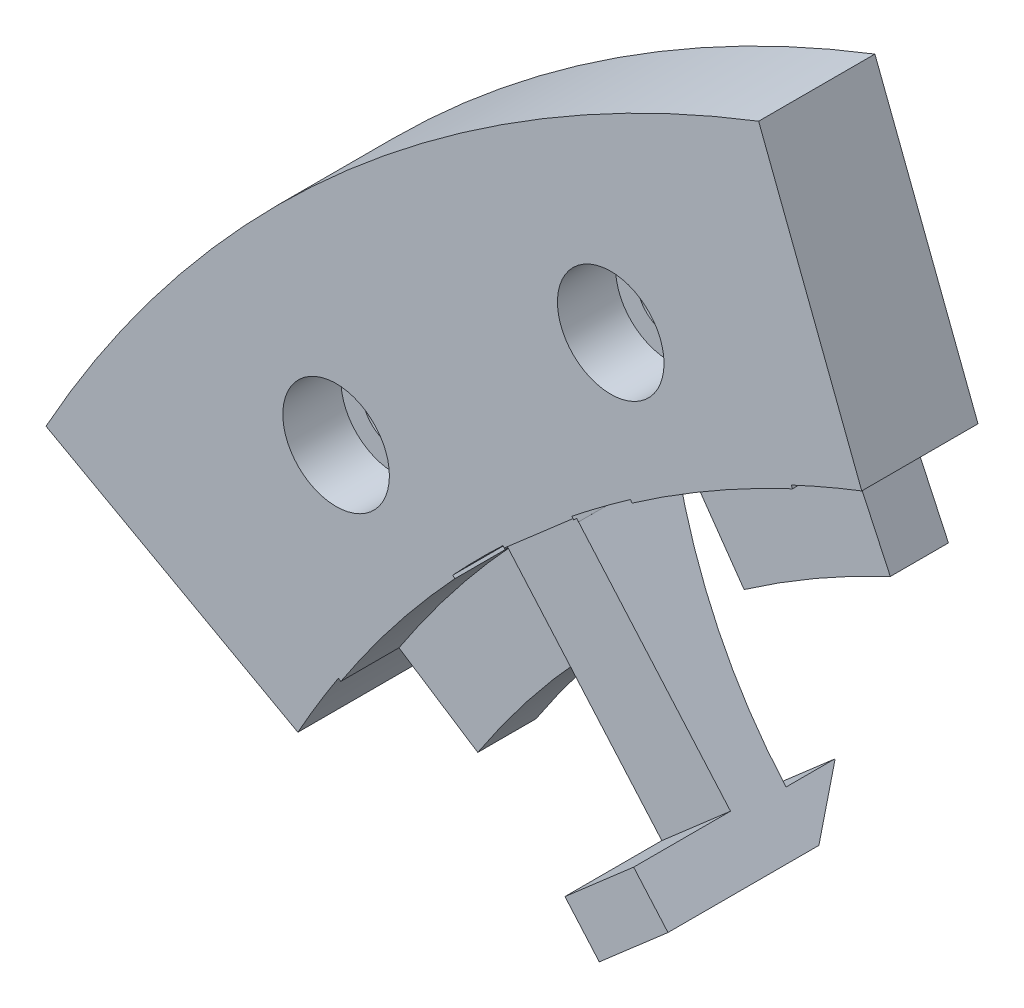
from build123d import *

# Parameters (mm, degrees)
BOSS_EXTRUDE1_DEPTH      = 6
SKETCH4_R                = 1.65
CUT_EXTRUDE1_DEPTH       = 92.758963041
BOSS_EXTRUDE2_DEPTH      = 2.5
BOSS_EXTRUDE2_DEPTH_BACK = 2.5
FILLET1_R                = 0.1
BOSS_EXTRUDE3_DEPTH      = 3
SKETCH9_R                = 2.75
CUT_EXTRUDE2_DEPTH       = 3
TOLERANCECUT_DEPTH       = 93.220969961
TOLERANCECUT2_DEPTH      = 2.35
TOLERANCECUT2_DEPTH_BACK = 2.35
CUT_EXTRUDE_THIN1_DEPTH  = 10


with BuildPart() as part:
    # Sketch1 → Boss-Extrude1 (new body)
    with BuildSketch(Plane(origin=(0, 0, 0), x_dir=(0, 1, 0), z_dir=(0, 0, 1))):
        with BuildLine():
            Line((66.793011614, 25.63943495), (52.789305216, 20.263915707))
            ThreePointArc((52.789305216, 20.263915707), (42.645904251, 37.130363258), (27.335841873, 49.498371429))
            Line((27.335841873, 49.498371429), (34.587369472, 62.629073903))
            ThreePointArc((34.587369472, 62.629073903), (53.95881545, 46.980136869), (66.793011614, 25.63943495))
        make_face()
    extrude(amount=BOSS_EXTRUDE1_DEPTH)

    # Sketch4 → Cut-Extrude1 (cut, through all)
    with BuildSketch(Plane(origin=(0, 0, 0), x_dir=(0, 1, 0), z_dir=(0, 0, 1))):
        with Locations((41.364521778, 47.584439033)):
            Circle(SKETCH4_R)
        with Locations((53.469432463, 33.41140961)):
            Circle(SKETCH4_R)
    extrude(amount=CUT_EXTRUDE1_DEPTH, mode=Mode.SUBTRACT)

    # Sketch7 → Boss-Extrude2 (add, two sides: drawn at the far end of the back side and taken through both)
    with BuildSketch(Plane(origin=(0, 0, 0), x_dir=(0, 0, 1), z_dir=(-0.7541940799479068, -0.6566515741026824, 0)).offset(-BOSS_EXTRUDE2_DEPTH_BACK)):
        with BuildLine():
            Line((6, 41.545), (3, 41.545))
            Line((3, 41.545), (0.5, 44.045))
            Line((0.5, 44.045), (0.5, 44.295))
            Line((0.5, 44.295), (3, 44.295))
            ThreePointArc((3, 44.295), (2.368624388, 50.546249875), (0.5, 56.545))
            Line((0.5, 56.545), (6, 56.545))
            Line((6, 56.545), (6, 44.545))
            Line((6, 44.545), (11, 44.545))
            Line((11, 44.545), (11, 41.545))
            Line((11, 41.545), (6, 41.545))
        make_face()
    extrude(amount=BOSS_EXTRUDE2_DEPTH + BOSS_EXTRUDE2_DEPTH_BACK)

    # Fillet1
    fillet1_edges = [part.edges().sort_by_distance(p)[0] for p in [
        (-29.086381475, 33.407026771, 3),
        (-29.250544368, 33.595575291, 6),
        (-37.130363258, 42.645904251, 0.5),
    ]]
    fillet(fillet1_edges, radius=FILLET1_R)

    # Sketch8 → Boss-Extrude3 (add)
    with BuildSketch(Plane(origin=(0, 0, 0), x_dir=(0, 1, 0), z_dir=(0, 0, 1))):
        with BuildLine():
            ThreePointArc((38.56359727, 41.354395058), (34.812578122, 44.558068063), (30.796614235, 47.422627264))
            Line((30.796614235, 47.422627264), (28.07341906, 43.229274425))
            ThreePointArc((28.07341906, 43.229274425), (31.734270746, 40.618014295), (35.153605469, 37.69762655))
            Line((35.153605469, 37.69762655), (38.56359727, 41.354395058))
        make_face()
        with BuildLine():
            ThreePointArc((51.247173818, 23.89694961), (48.969406457, 28.2725), (46.318952344, 32.432879593))
            Line((46.318952344, 32.432879593), (42.223192123, 29.564997412))
            ThreePointArc((42.223192123, 29.564997412), (44.639279438, 25.7725), (46.715634883, 21.783858301))
            Line((46.715634883, 21.783858301), (51.247173818, 23.89694961))
        make_face()
    extrude(amount=BOSS_EXTRUDE3_DEPTH)

    # Sketch9 → Cut-Extrude2 (cut)
    with BuildSketch(Plane.XY.offset(6)):
        with Locations((-47.584439033, 41.364521778)):
            Circle(SKETCH9_R)
        with Locations((-33.41140961, 53.469432463)):
            Circle(SKETCH9_R)
    extrude(amount=-CUT_EXTRUDE2_DEPTH, mode=Mode.SUBTRACT)

    # Sketch10 → ToleranceCut (cut, through all)
    with BuildSketch(Plane(origin=(0, 0, 0), x_dir=(0, 1, 0), z_dir=(0, 0, 1))):
        with BuildLine():
            Line((38.453894214, 41.456694812), (35.14605375, 37.9094702))
            ThreePointArc((35.14605375, 37.9094702), (31.826619967, 40.736215908), (28.280796974, 43.273196641))
            Line((28.280796974, 43.273196641), (30.92241482, 47.340931409))
            Line((30.92241482, 47.340931409), (30.67081365, 47.50432312))
            Line((30.67081365, 47.50432312), (27.865803402, 43.184986115))
            ThreePointArc((27.865803402, 43.184986115), (31.641921524, 40.499812682), (35.160859486, 37.485463652))
            Line((35.160859486, 37.485463652), (38.673300325, 41.252095304))
            Line((38.673300325, 41.252095304), (38.453894214, 41.456694812))
        make_face()
        with BuildLine():
            Line((46.232915879, 32.5557524), (42.014103544, 29.601708201))
            ThreePointArc((42.014103544, 29.601708201), (44.509375628, 25.6975), (46.642883069, 21.584426886))
            Line((46.642883069, 21.584426886), (51.310566557, 23.761003442))
            Line((51.310566557, 23.761003442), (51.183781079, 24.032895778))
            Line((51.183781079, 24.032895778), (46.787991078, 21.983105237))
            ThreePointArc((46.787991078, 21.983105237), (44.769183249, 25.8475), (42.431923129, 29.528036247))
            Line((42.431923129, 29.528036247), (46.40498881, 32.310006787))
            Line((46.40498881, 32.310006787), (46.232915879, 32.5557524))
        make_face()
        Polygon((44.147333984, 35.321699097), (32.876124251, 25.508233558), (33.073119723, 25.281975334), (44.344329456, 35.095440873), align=None)
        Polygon((40.817854097, 39.052425533), (29.59286638, 29.279203958), (29.789861852, 29.052945734), (41.014849569, 38.826167309), align=None)
    extrude(amount=TOLERANCECUT_DEPTH, mode=Mode.SUBTRACT)

    # Sketch16 → ToleranceCut2 (cut, two sides: drawn at the far end of the back side and taken through both)
    with BuildSketch(Plane(origin=(0, 0, 0), x_dir=(0, 0, 1), z_dir=(-0.7541940799479068, -0.6566515741026824, 0)).offset(-TOLERANCECUT2_DEPTH_BACK)):
        with BuildLine():
            Line((5.85, 56.545), (5.85, 44.395))
            Line((5.85, 44.395), (10.85, 44.395))
            Line((10.85, 44.395), (10.85, 41.695))
            Line((10.85, 41.695), (6, 41.695))
            Line((6, 41.695), (3.062132034, 41.695))
            Line((3.062132034, 41.695), (0.65, 44.107132034))
            Line((0.65, 44.107132034), (0.65, 44.145))
            Line((0.65, 44.145), (3.14964186, 44.145))
            ThreePointArc((3.14964186, 44.145), (2.530504313, 50.50274046), (0.638004798, 56.603776489))
            Line((0.638004798, 56.603776489), (0.361995202, 56.486223511))
            ThreePointArc((0.361995202, 56.486223511), (2.206568162, 50.589723315), (2.849638407, 44.445))
            Line((2.849638407, 44.445), (0.35, 44.445))
            Line((0.35, 44.445), (0.35, 43.982867966))
            Line((0.35, 43.982867966), (2.937867966, 41.395))
            Line((2.937867966, 41.395), (6, 41.395))
            Line((6, 41.395), (11.15, 41.395))
            Line((11.15, 41.395), (11.15, 44.695))
            Line((11.15, 44.695), (6.15, 44.695))
            Line((6.15, 44.695), (6.15, 56.545))
            Line((6.15, 56.545), (5.85, 56.545))
        make_face()
    extrude(amount=TOLERANCECUT2_DEPTH + TOLERANCECUT2_DEPTH_BACK, mode=Mode.SUBTRACT)

    # Sketch17 → Cut-Extrude-Thin1 (cut)
    with BuildSketch(Plane(origin=(0, 0, 0), x_dir=(0, 1, 0), z_dir=(0, 0, 1))):
        with BuildLine():
            ThreePointArc((51.047913396, 23.969100589), (51.912040519, 22.035137719), (52.70292998, 20.070087611))
            Line((52.70292998, 20.070087611), (66.846766806, 25.499397886))
            Line((66.846766806, 25.499397886), (66.739256421, 25.779472014))
            Line((66.739256421, 25.779472014), (52.875494708, 20.457672502))
            ThreePointArc((52.875494708, 20.457672502), (52.129243688, 22.290721328), (51.319468445, 24.096606884))
            Line((51.319468445, 24.096606884), (51.047913396, 23.969100589))
        make_face()
        with BuildLine():
            ThreePointArc((31.004335746, 47.466347973), (29.290610597, 48.542591153), (27.539568245, 49.556989475))
            Line((27.539568245, 49.556989475), (34.718676497, 62.556558627))
            Line((34.718676497, 62.556558627), (34.456062447, 62.701589179))
            Line((34.456062447, 62.701589179), (27.131923134, 49.439405054))
            ThreePointArc((27.131923134, 49.439405054), (29.007426552, 48.362849687), (30.840277175, 47.215181126))
            Line((30.840277175, 47.215181126), (31.004335746, 47.466347973))
        make_face()
        with BuildLine():
            ThreePointArc((38.351817991, 41.346648013), (39.675403143, 40.078293758), (40.957064996, 38.767590486))
            Line((40.957064996, 38.767590486), (41.174940656, 38.973818992))
            ThreePointArc((41.174940656, 38.973818992), (39.88646086, 40.291494696), (38.55583475, 41.566596103))
            Line((38.55583475, 41.566596103), (38.351817991, 41.346648013))
        make_face()
        with BuildLine():
            ThreePointArc((44.030208622, 35.227988641), (45.178364811, 33.742937157), (46.276455334, 32.220492496))
            Line((46.276455334, 32.220492496), (46.522656602, 32.391912844))
            ThreePointArc((46.522656602, 32.391912844), (45.418723987, 33.922457258), (44.264459346, 35.415409553))
            Line((44.264459346, 35.415409553), (44.030208622, 35.227988641))
        make_face()
    extrude(amount=CUT_EXTRUDE_THIN1_DEPTH, mode=Mode.SUBTRACT)


solid = part.part
